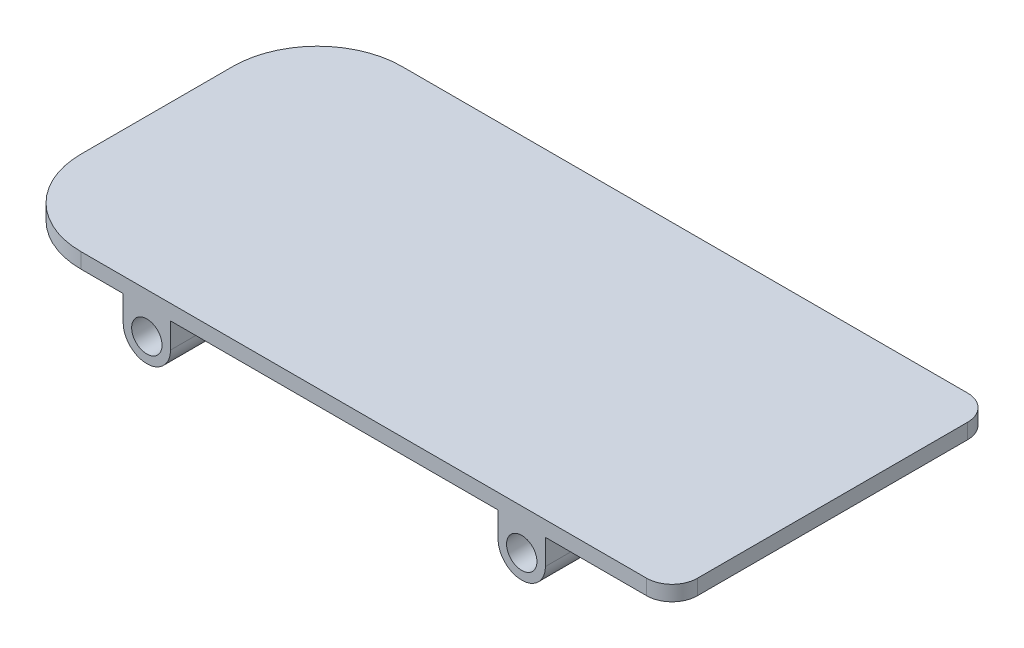
from build123d import *

# Parameters (mm, degrees)
IZIM1_R                     = 18
Y_KSEKLIK_EKSTR_ZYON1_DEPTH = 380
RADYUS1_R                   = 100
RADYUS2_R                   = 30


with BuildPart() as part:
    # Çizim1 → Yükseklik-Ekstrüzyon1 (new body)
    with BuildSketch(Plane.XY):
        with BuildLine():
            Line((-28, 0), (-28, 30))
            Line((-28, 30), (-178, 30))
            Line((-178, 30), (-178, 48))
            Line((-178, 48), (622, 48))
            Line((622, 48), (622, 30))
            Line((622, 30), (472, 30))
            Line((472, 30), (472, 0))
            ThreePointArc((472, 0), (444, -28), (416, 0))
            Line((416, 0), (416, 30))
            Line((416, 30), (28, 30))
            Line((28, 30), (28, 0))
            ThreePointArc((28, 0), (0, -28), (-28, 0))
        make_face()
        Circle(IZIM1_R, mode=Mode.SUBTRACT)
        with Locations((444, 0)):
            Circle(IZIM1_R, mode=Mode.SUBTRACT)
    extrude(amount=Y_KSEKLIK_EKSTR_ZYON1_DEPTH)

    # Radyus1
    radyus1_edges = [part.edges().sort_by_distance(p)[0] for p in [
        (-178, 39, 0),
        (-178, 39, 380),
    ]]
    fillet(radyus1_edges, radius=RADYUS1_R)

    # Radyus2
    radyus2_edges = [part.edges().sort_by_distance(p)[0] for p in [
        (622, 39, 0),
        (622, 39, 380),
    ]]
    fillet(radyus2_edges, radius=RADYUS2_R)


solid = part.part
